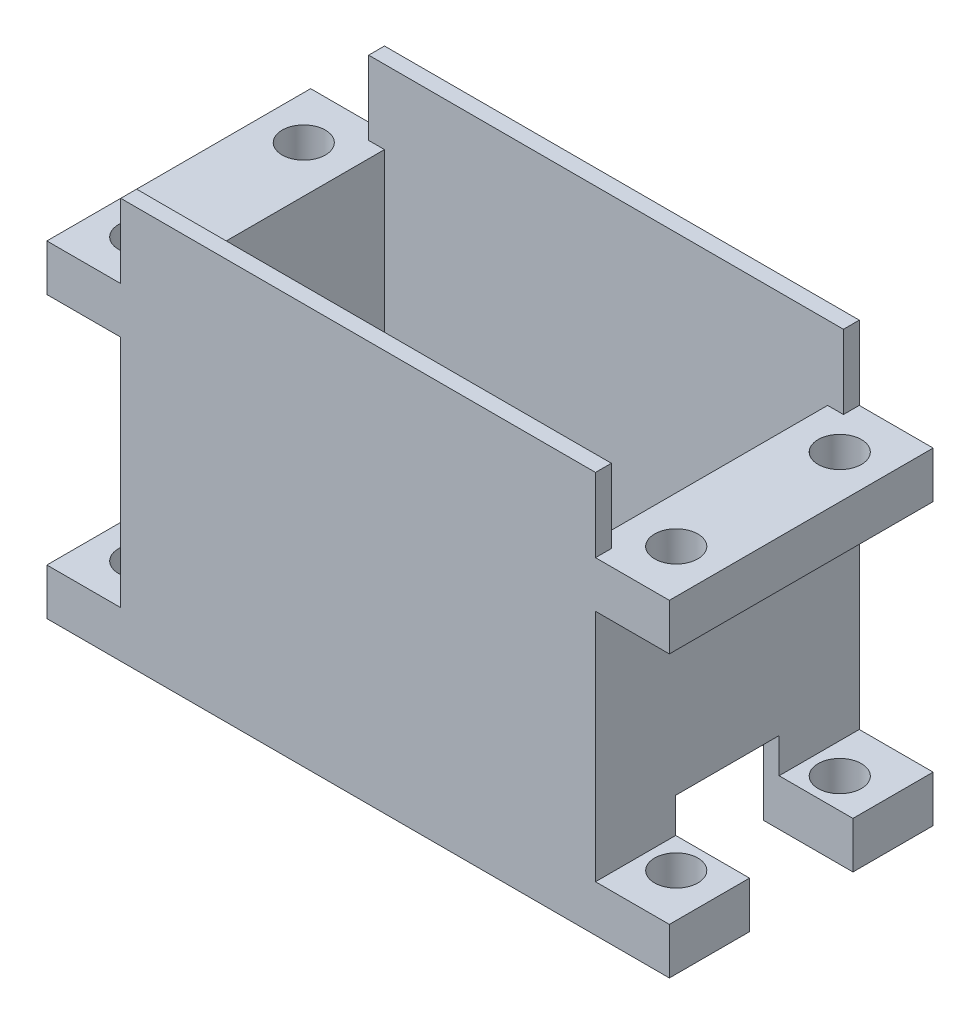
from build123d import *

# Parameters (mm, degrees)
SKETCH1_W               = 45
SKETCH1_H               = 25
SKETCH1_W_2             = 42
SKETCH1_H_2             = 22
BOSS_EXTRUDE1_DEPTH     = 38
CUT_EXTRUDE2_START      = -46
SKETCH3_W               = 21.995206391
SKETCH3_H               = 7
CUT_EXTRUDE2_DEPTH      = 47
SKETCH4_W               = 25
SKETCH4_H               = 4.4
BOSS_EXTRUDE3_DEPTH     = 7
SKETCH8_R               = 2.05
CUT_EXTRUDE5_DEPTH      = 4.4
SKETCH6_W               = 9.8
SKETCH6_H               = 10.757060019
CUT_EXTRUDE4_DEPTH      = 8
CUT_EXTRUDE4_DEPTH_BACK = 7
MIRROR2_START           = -46
MIRROR2_COPY_1_SKETCH_W = 21.995206391
MIRROR2_COPY_1_SKETCH_H = 7
MIRROR2_COPY_1_DEPTH    = 47
MIRROR2_COPY_2_SKETCH_W = 25
MIRROR2_COPY_2_SKETCH_H = 4.4
MIRROR2_COPY_2_DEPTH    = 7
MIRROR2_COPY_3_SKETCH_R = 2.05
MIRROR2_COPY_3_DEPTH    = 4.4
SKETCH6_2_W             = 9.8
SKETCH6_2_H             = 10.757060019
CUT_EXTRUDE6_DEPTH      = 15


with BuildPart() as part:
    # Sketch1 → Boss-Extrude1 (new body)
    with BuildSketch(Plane(origin=(0, 0, 0), x_dir=(1, 0, 0), z_dir=(0, 1, 0))):
        with Locations((21, 11)):
            Rectangle(SKETCH1_W, SKETCH1_H)
        with Locations((21, 11)):
            Rectangle(SKETCH1_W_2, SKETCH1_H_2, mode=Mode.SUBTRACT)
    extrude(amount=BOSS_EXTRUDE1_DEPTH)

    # Sketch3 → Cut-Extrude2 (cut)
    with BuildSketch(Plane(origin=(43.5, 0, 0), x_dir=(0, 0, -1), z_dir=(1, 0, 0)).offset(CUT_EXTRUDE2_START)):
        with Locations((11.002396805, 34.5)):
            Rectangle(SKETCH3_W, SKETCH3_H)
    cut_extrude2 = extrude(amount=CUT_EXTRUDE2_DEPTH, mode=Mode.SUBTRACT)

    # Sketch4 → Boss-Extrude3 (add)
    with BuildSketch(Plane(origin=(43.5, 0, 0), x_dir=(0, 0, -1), z_dir=(1, 0, 0))):
        with Locations((11, 28.8)):
            Rectangle(SKETCH4_W, SKETCH4_H)
    boss_extrude3 = extrude(amount=BOSS_EXTRUDE3_DEPTH)

    # Sketch8 → Cut-Extrude5 (cut)
    with BuildSketch(Plane(origin=(0, 31, 0), x_dir=(1, 0, 0), z_dir=(0, 1, 0))):
        with Locations((46.4, 18.75)):
            Circle(SKETCH8_R)
        with Locations((46.399285585, 3.250377991)):
            Circle(SKETCH8_R)
    cut_extrude5 = extrude(amount=-CUT_EXTRUDE5_DEPTH, mode=Mode.SUBTRACT)

    # Mirror1: Cut-Extrude2, Boss-Extrude3, Cut-Extrude5 across plane
    add(cut_extrude2.mirror(Plane(origin=(21, 0, 0), x_dir=(0, 0, 1), z_dir=(1, 0, 0))), mode=Mode.SUBTRACT)
    add(boss_extrude3.mirror(Plane(origin=(21, 0, 0), x_dir=(0, 0, 1), z_dir=(1, 0, 0))))
    add(cut_extrude5.mirror(Plane(origin=(21, 0, 0), x_dir=(0, 0, 1), z_dir=(1, 0, 0))), mode=Mode.SUBTRACT)

    # Sketch6 → Cut-Extrude4 (cut, two sides)
    with BuildSketch(Plane(origin=(43.5, 0, 0), x_dir=(0, 0, -1), z_dir=(1, 0, 0))) as cut_extrude4_sk:
        with Locations((11, 2.32146999)):
            Rectangle(SKETCH6_W, SKETCH6_H)
    extrude(amount=CUT_EXTRUDE4_DEPTH, mode=Mode.SUBTRACT)
    extrude(cut_extrude4_sk.sketch, amount=-CUT_EXTRUDE4_DEPTH_BACK, mode=Mode.SUBTRACT)

    # Mirror2: Cut-Extrude2, Boss-Extrude3, Cut-Extrude5 across plane
    add(cut_extrude2.mirror(Plane.ZX.offset(15.5)), mode=Mode.SUBTRACT)
    add(boss_extrude3.mirror(Plane.ZX.offset(15.5)))
    add(cut_extrude5.mirror(Plane.ZX.offset(15.5)), mode=Mode.SUBTRACT)

    # Mirror2 copy 1 sketch → Mirror2 copy 1 (cut)
    with BuildSketch(Plane(origin=(-1.5, 31, 0), x_dir=(0, 0, -1), z_dir=(-1, 0, 0)).offset(MIRROR2_START)):
        with Locations((11.002396805, 34.5)):
            Rectangle(MIRROR2_COPY_1_SKETCH_W, MIRROR2_COPY_1_SKETCH_H)
    extrude(amount=MIRROR2_COPY_1_DEPTH, mode=Mode.SUBTRACT)

    # Mirror2 copy 2 sketch → Mirror2 copy 2 (add)
    with BuildSketch(Plane(origin=(-1.5, 31, 0), x_dir=(0, 0, -1), z_dir=(-1, 0, 0))):
        with Locations((11, 28.8)):
            Rectangle(MIRROR2_COPY_2_SKETCH_W, MIRROR2_COPY_2_SKETCH_H)
    extrude(amount=MIRROR2_COPY_2_DEPTH)

    # Mirror2 copy 3 sketch → Mirror2 copy 3 (cut)
    with BuildSketch(Plane(origin=(42, 0, 0), x_dir=(-1, 0, 0), z_dir=(0, -1, 0))):
        with Locations((46.4, 18.75)):
            Circle(MIRROR2_COPY_3_SKETCH_R)
        with Locations((46.399285585, 3.250377991)):
            Circle(MIRROR2_COPY_3_SKETCH_R)
    extrude(amount=-MIRROR2_COPY_3_DEPTH, mode=Mode.SUBTRACT)

    # Sketch6_2 → Cut-Extrude6 (cut)
    with BuildSketch(Plane(origin=(43.5, 0, 0), x_dir=(0, 0, -1), z_dir=(1, 0, 0))):
        with Locations((11, 2.32146999)):
            Rectangle(SKETCH6_2_W, SKETCH6_2_H)
    extrude(amount=CUT_EXTRUDE6_DEPTH, mode=Mode.SUBTRACT)


solid = part.part
